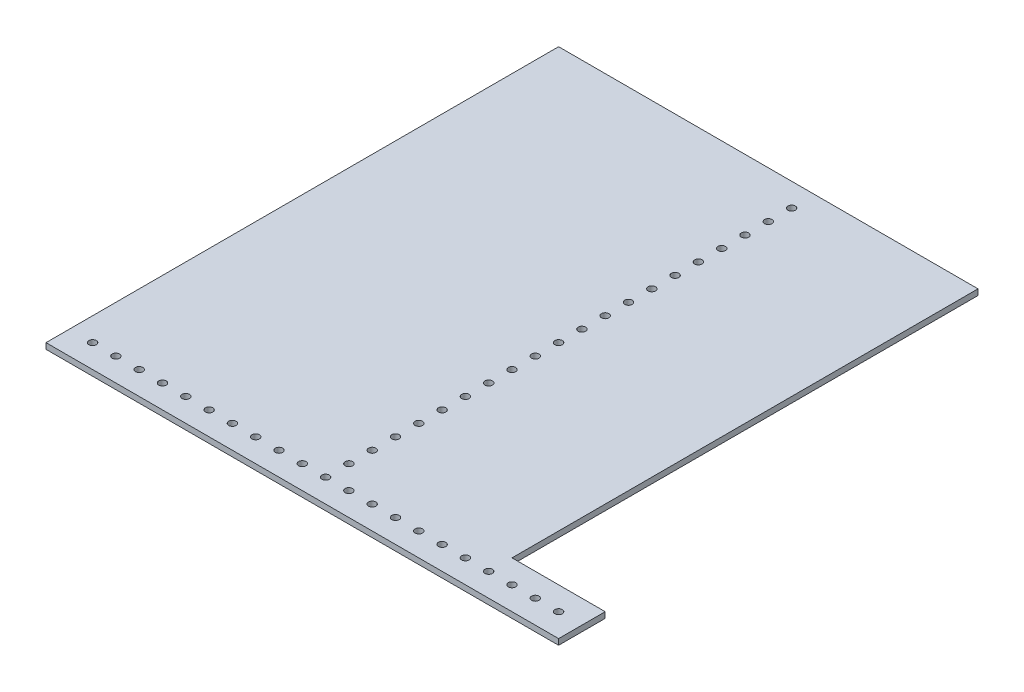
from build123d import *

# Parameters (mm, degrees)
SKETCH1_W           = 279.4
SKETCH1_H           = 279.4
SKETCH1_R           = 2.0193
BOSS_EXTRUDE1_DEPTH = 3.175
SKETCH2_W           = 50.8
SKETCH2_H           = 254
CUT_EXTRUDE1_DEPTH  = 4.175


with BuildPart() as part:
    # Sketch1 → Boss-Extrude1 (new body)
    with BuildSketch(Plane(origin=(0, 0, 0), x_dir=(1, 0, 0), z_dir=(0, 1, 0))):
        with Locations((139.7, 139.7)):
            Rectangle(SKETCH1_W, SKETCH1_H)
        with Locations((12.7, 12.7)):
            Circle(SKETCH1_R, mode=Mode.SUBTRACT)
        with Locations((25.4, 12.7)):
            Circle(SKETCH1_R, mode=Mode.SUBTRACT)
        with Locations((38.1, 12.7)):
            Circle(SKETCH1_R, mode=Mode.SUBTRACT)
        with Locations((50.8, 12.7)):
            Circle(SKETCH1_R, mode=Mode.SUBTRACT)
        with Locations((63.5, 12.7)):
            Circle(SKETCH1_R, mode=Mode.SUBTRACT)
        with Locations((76.2, 12.7)):
            Circle(SKETCH1_R, mode=Mode.SUBTRACT)
        with Locations((88.9, 12.7)):
            Circle(SKETCH1_R, mode=Mode.SUBTRACT)
        with Locations((101.6, 12.7)):
            Circle(SKETCH1_R, mode=Mode.SUBTRACT)
        with Locations((114.3, 12.7)):
            Circle(SKETCH1_R, mode=Mode.SUBTRACT)
        with Locations((127, 12.7)):
            Circle(SKETCH1_R, mode=Mode.SUBTRACT)
        with Locations((139.7, 12.7)):
            Circle(SKETCH1_R, mode=Mode.SUBTRACT)
        with Locations((139.7, 25.4)):
            Circle(SKETCH1_R, mode=Mode.SUBTRACT)
        with Locations((139.7, 38.1)):
            Circle(SKETCH1_R, mode=Mode.SUBTRACT)
        with Locations((139.7, 50.8)):
            Circle(SKETCH1_R, mode=Mode.SUBTRACT)
        with Locations((139.7, 63.5)):
            Circle(SKETCH1_R, mode=Mode.SUBTRACT)
        with Locations((139.7, 76.2)):
            Circle(SKETCH1_R, mode=Mode.SUBTRACT)
        with Locations((139.7, 88.9)):
            Circle(SKETCH1_R, mode=Mode.SUBTRACT)
        with Locations((139.7, 101.6)):
            Circle(SKETCH1_R, mode=Mode.SUBTRACT)
        with Locations((139.7, 114.3)):
            Circle(SKETCH1_R, mode=Mode.SUBTRACT)
        with Locations((139.7, 127)):
            Circle(SKETCH1_R, mode=Mode.SUBTRACT)
        with Locations((139.7, 139.7)):
            Circle(SKETCH1_R, mode=Mode.SUBTRACT)
        with Locations((139.7, 152.4)):
            Circle(SKETCH1_R, mode=Mode.SUBTRACT)
        with Locations((139.7, 165.1)):
            Circle(SKETCH1_R, mode=Mode.SUBTRACT)
        with Locations((139.7, 177.8)):
            Circle(SKETCH1_R, mode=Mode.SUBTRACT)
        with Locations((139.7, 190.5)):
            Circle(SKETCH1_R, mode=Mode.SUBTRACT)
        with Locations((139.7, 203.2)):
            Circle(SKETCH1_R, mode=Mode.SUBTRACT)
        with Locations((139.7, 215.9)):
            Circle(SKETCH1_R, mode=Mode.SUBTRACT)
        with Locations((139.7, 228.6)):
            Circle(SKETCH1_R, mode=Mode.SUBTRACT)
        with Locations((139.7, 241.3)):
            Circle(SKETCH1_R, mode=Mode.SUBTRACT)
        with Locations((139.7, 254)):
            Circle(SKETCH1_R, mode=Mode.SUBTRACT)
        with Locations((139.7, 266.7)):
            Circle(SKETCH1_R, mode=Mode.SUBTRACT)
        with Locations((152.4, 12.7)):
            Circle(SKETCH1_R, mode=Mode.SUBTRACT)
        with Locations((165.1, 12.7)):
            Circle(SKETCH1_R, mode=Mode.SUBTRACT)
        with Locations((177.8, 12.7)):
            Circle(SKETCH1_R, mode=Mode.SUBTRACT)
        with Locations((190.5, 12.7)):
            Circle(SKETCH1_R, mode=Mode.SUBTRACT)
        with Locations((203.2, 12.7)):
            Circle(SKETCH1_R, mode=Mode.SUBTRACT)
        with Locations((215.9, 12.7)):
            Circle(SKETCH1_R, mode=Mode.SUBTRACT)
        with Locations((228.6, 12.7)):
            Circle(SKETCH1_R, mode=Mode.SUBTRACT)
        with Locations((241.3, 12.7)):
            Circle(SKETCH1_R, mode=Mode.SUBTRACT)
        with Locations((254, 12.7)):
            Circle(SKETCH1_R, mode=Mode.SUBTRACT)
        with Locations((266.7, 12.7)):
            Circle(SKETCH1_R, mode=Mode.SUBTRACT)
    extrude(amount=BOSS_EXTRUDE1_DEPTH)

    # Sketch2 → Cut-Extrude1 (cut, through all)
    with BuildSketch(Plane(origin=(0, 3.175, 0), x_dir=(1, 0, 0), z_dir=(0, 1, 0))):
        with Locations((254, 152.4)):
            Rectangle(SKETCH2_W, SKETCH2_H)
    extrude(amount=-CUT_EXTRUDE1_DEPTH, mode=Mode.SUBTRACT)


solid = part.part
